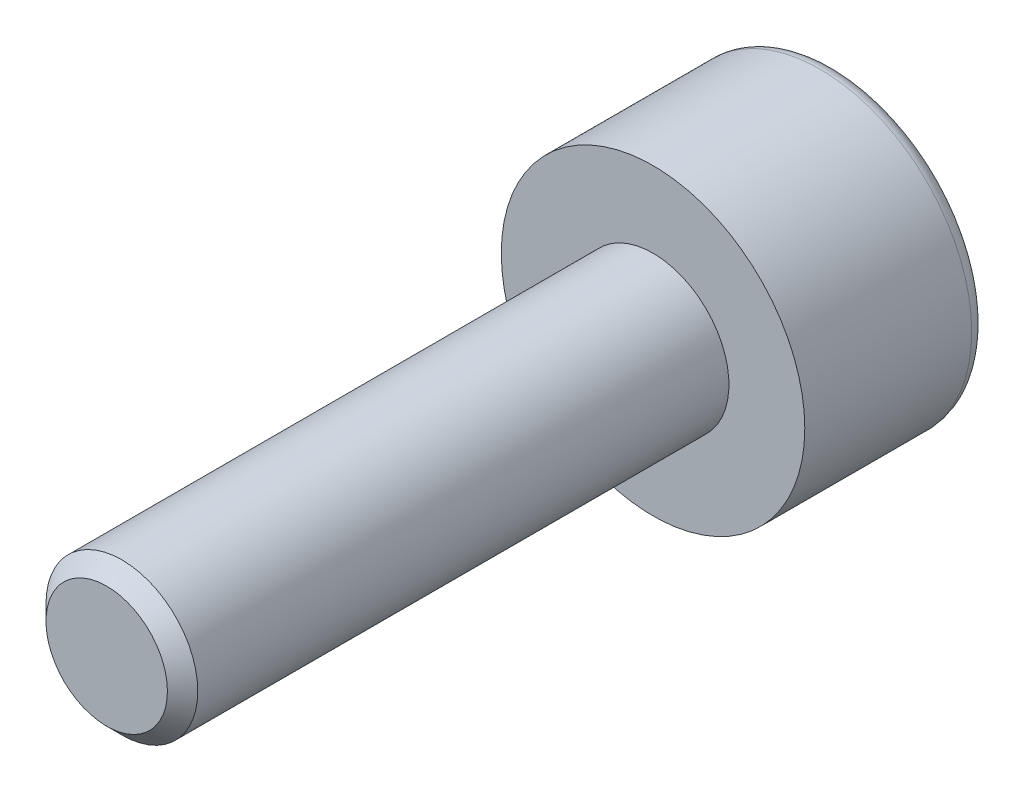
from build123d import *

# Parameters (mm, degrees)
ESQUISSE1_R             = 2.5
BASE_EXTRUSION_DEPTH    = 18
CHANFREIN1_SIZE         = 0.5
ESQUISSE2_R             = 5
BOSS_EXTRU_1_DEPTH      = 6
ENL_V_MAT_EXTRU_1_DEPTH = 3
ESQUISSE4_R             = 3
ENL_V_MAT_EXTRU_2_DEPTH = 0.5
ENL_V_MAT_EXTRU_2_DRAFT = -45
CONG_1_R                = 0.5


with BuildPart() as part:
    # Esquisse1 → Base-Extrusion (new body)
    with BuildSketch(Plane.XY):
        with Locations(Location((0, 0, 0), (0, 0, 180))):  # turned: the seam where the file's is
            Circle(ESQUISSE1_R)
    extrude(amount=BASE_EXTRUSION_DEPTH)

    # Chanfrein1
    chanfrein1_edges = [part.edges().sort_by_distance(p)[0] for p in [
        (2.5, 0, 18),
    ]]
    chamfer(chanfrein1_edges, length=CHANFREIN1_SIZE)

    # Esquisse2 → Boss.-Extru.1 (add)
    with BuildSketch(Plane(origin=(0, 0, 0), x_dir=(-1, 0, 0), z_dir=(0, 0, -1))):
        Circle(ESQUISSE2_R)
    extrude(amount=BOSS_EXTRU_1_DEPTH)

    # Esquisse3 → Enlèv. mat.-Extru.1 (cut)
    with BuildSketch(Plane(origin=(0, 0, -6), x_dir=(-1, 0, 0), z_dir=(0, 0, -1))):
        Polygon((-3, 0), (-1.5, 2.598076211), (1.5, 2.598076211), (3, 0), (1.5, -2.598076211), (-1.5, -2.598076211), align=None)
    extrude(amount=-ENL_V_MAT_EXTRU_1_DEPTH, mode=Mode.SUBTRACT)


with BuildPart() as enl_v_mat_extru_2_tool:
    # Esquisse4 → Enlèv. mat.-Extru.2 (with draft: the straight prism first)
    with BuildSketch(Plane(origin=(0, 0, -6), x_dir=(-1, 0, 0), z_dir=(0, 0, -1))):
        Circle(ESQUISSE4_R)
    extrude(amount=-ENL_V_MAT_EXTRU_2_DEPTH)
    # Enlèv. mat.-Extru.2: the draft: its side faces are tilted about the plane it starts from
    enl_v_mat_extru_2_sides = [enl_v_mat_extru_2_tool.faces().sort_by_distance(p)[0] for p in [
        (3, 0, -5.75),
    ]]
    draft(enl_v_mat_extru_2_sides, Plane(origin=(0, 0, -6), x_dir=(-1, 0, 0), z_dir=(0, 0, -1)), ENL_V_MAT_EXTRU_2_DRAFT)


with BuildPart() as part_1:
    add(part.part)

    # Enlèv. mat.-Extru.2: cut by enl_v_mat_extru_2_tool
    add(enl_v_mat_extru_2_tool.part, mode=Mode.SUBTRACT)

    # Congé1
    cong_1_edges = [part_1.edges().sort_by_distance(p)[0] for p in [
        (5, 0, -6),
    ]]
    fillet(cong_1_edges, radius=CONG_1_R)


solid = part_1.part
